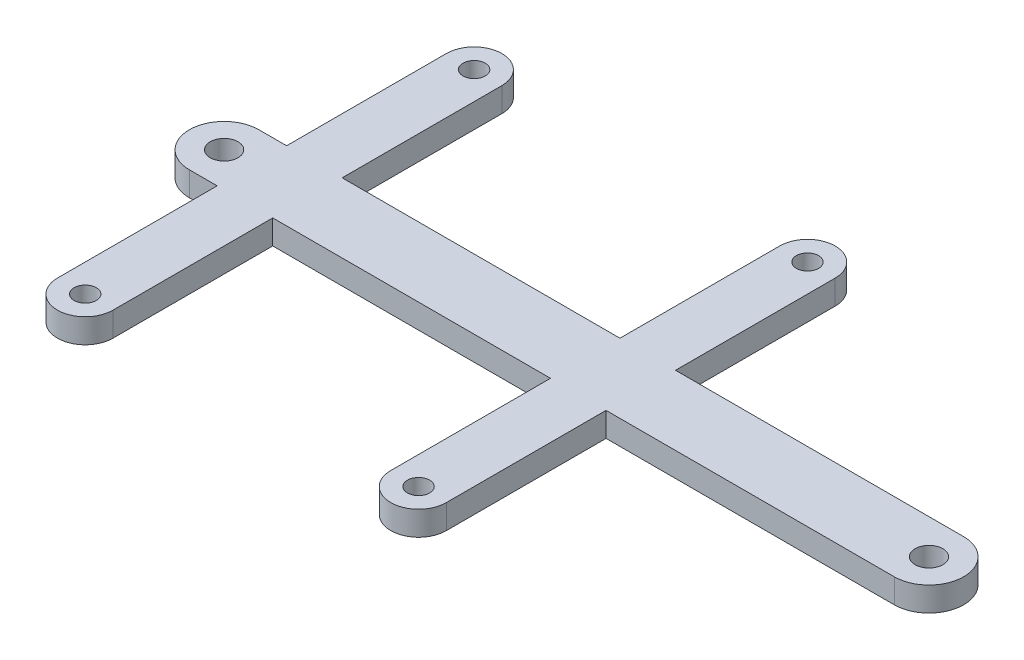
from build123d import *

# Parameters (mm, degrees)
SKETCH1_R           = 2
SKETCH1_R_2         = 1.6
BOSS_EXTRUDE1_DEPTH = 3.5


with BuildPart() as part:
    # Sketch1 → Boss-Extrude1 (new body)
    with BuildSketch(Plane(origin=(0, 0, 0), x_dir=(1, 0, 0), z_dir=(0, 1, 0))):
        with BuildLine():
            Line((10, 28), (10, 5))
            Line((10, 5), (51.5, 5))
            ThreePointArc((51.5, 5), (56.5, 0), (51.5, -5))
            Line((51.5, -5), (10, -5))
            Line((10, -5), (10, -28))
            ThreePointArc((10, -28), (6, -32), (2, -28))
            Line((2, -28), (2, -5))
            Line((2, -5), (-38, -5))
            Line((-38, -5), (-38, -28))
            ThreePointArc((-38, -28), (-42, -32), (-46, -28))
            Line((-46, -28), (-46, -5))
            Line((-46, -5), (-50, -5))
            ThreePointArc((-50, -5), (-55, 0), (-50, 5))
            Line((-50, 5), (-46, 5))
            Line((-46, 5), (-46, 28))
            ThreePointArc((-46, 28), (-42, 32), (-38, 28))
            Line((-38, 28), (-38, 5))
            Line((-38, 5), (2, 5))
            Line((2, 5), (2, 28))
            ThreePointArc((2, 28), (6, 32), (10, 28))
        make_face()
        with Locations((51.5, 0)):
            Circle(SKETCH1_R, mode=Mode.SUBTRACT)
        with Locations((-50, 0)):
            Circle(SKETCH1_R, mode=Mode.SUBTRACT)
        with Locations((6, 28)):
            Circle(SKETCH1_R_2, mode=Mode.SUBTRACT)
        with Locations((-42, 28)):
            Circle(SKETCH1_R_2, mode=Mode.SUBTRACT)
        with Locations((-42, -28)):
            Circle(SKETCH1_R_2, mode=Mode.SUBTRACT)
        with Locations((6, -28)):
            Circle(SKETCH1_R_2, mode=Mode.SUBTRACT)
    extrude(amount=BOSS_EXTRUDE1_DEPTH)


solid = part.part
